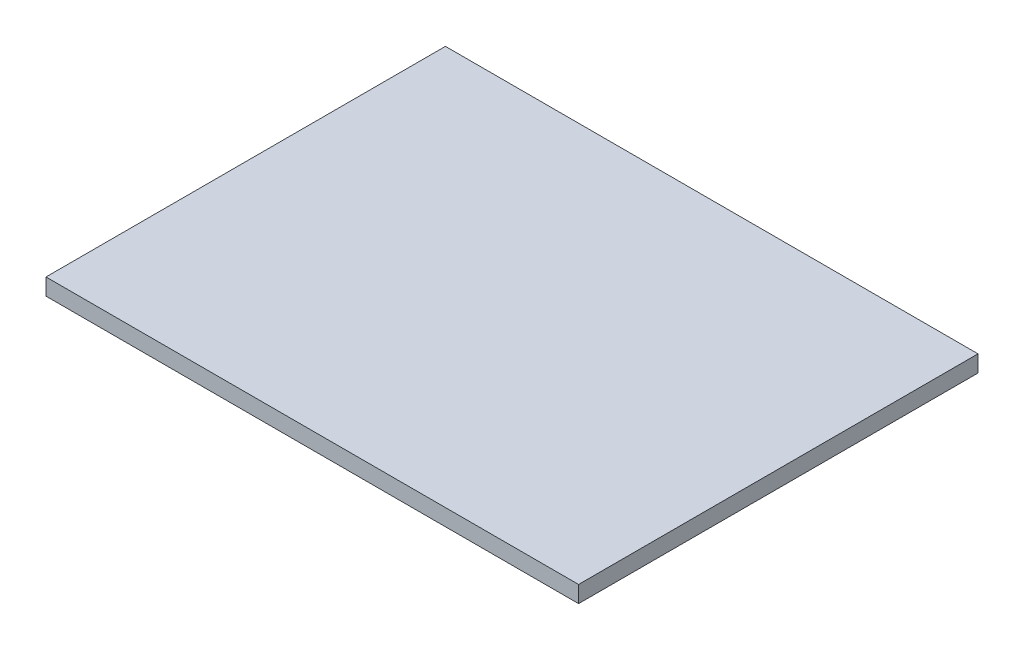
from build123d import *

# Parameters (mm, degrees)
SKETCH_1_W      = 80
SKETCH_1_H      = 60
EXTRUDE_1_DEPTH = 2.5


with BuildPart() as part:
    # Эскиз1 → Бобышка-Вытянуть1 (new body)
    with BuildSketch(Plane(origin=(0, 0, 0), x_dir=(1, 0, 0), z_dir=(0, 1, 0))):
        Rectangle(SKETCH_1_W, SKETCH_1_H)
    extrude(amount=EXTRUDE_1_DEPTH)


solid = part.part
